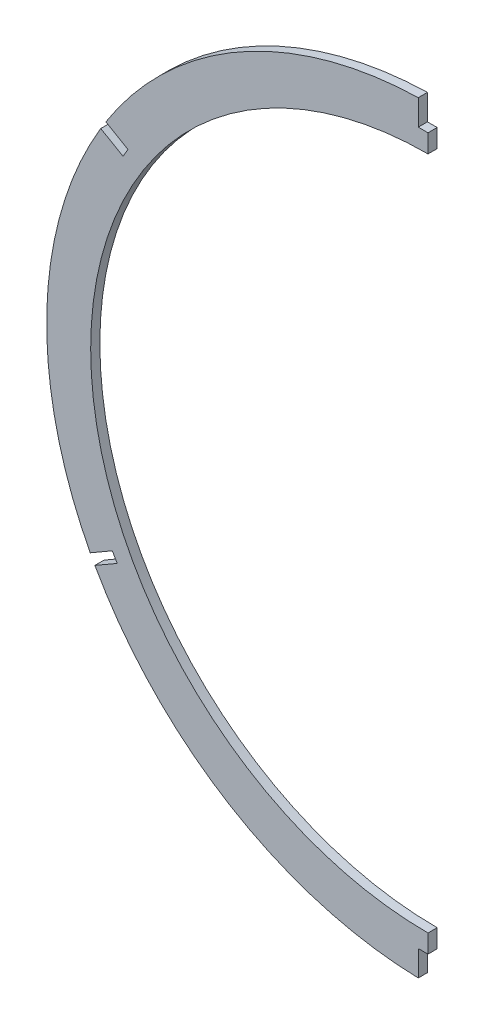
from build123d import *

# Parameters (mm, degrees)
SKETCH2_R           = 116.84
BOSS_EXTRUDE1_DEPTH = 1.5875
SKETCH3_W           = 232.210592103
SKETCH3_H           = 398.954583541
CUT_EXTRUDE1_DEPTH  = 133.08
SKETCH4_W           = 3.3782
SKETCH4_H           = 10.16
CUT_EXTRUDE2_DEPTH  = 4.175


with BuildPart() as part:
    # Sketch2 → Boss-Extrude1 (new body, symmetric)
    with BuildSketch(Plane.XY):
        with BuildLine():
            ThreePointArc((-1.651, 128.513680847), (-113.443755652, 64.087482344), (-116.974071472, -64.89271823))
            ThreePointArc((-116.974071472, -64.89271823), (-116.588202689, -65.623039511), (-116.197774242, -66.350933404))
            ThreePointArc((-116.197774242, -66.350933404), (-115.802941233, -67.076116512), (-115.403582459, -67.798817153))
            ThreePointArc((-115.403582459, -67.798817153), (0, -135.636), (115.403582459, -67.798817153))
            ThreePointArc((115.403582459, -67.798817153), (115.802941375, -67.076116254), (116.197774523, -66.350932884))
            ThreePointArc((116.197774523, -66.350932884), (116.588202828, -65.62303925), (116.974071472, -64.89271823))
            ThreePointArc((116.974071472, -64.89271823), (113.443755652, 64.087482344), (1.651, 128.513680847))
            ThreePointArc((1.651, 128.513680847), (0.825516124, 128.521420187), (0, 128.524))
            ThreePointArc((0, 128.524), (-0.825516124, 128.521420187), (-1.651, 128.513680847))
        make_face()
        with Locations((0, -3.556)):
            Circle(SKETCH2_R, mode=Mode.SUBTRACT)
    extrude(amount=BOSS_EXTRUDE1_DEPTH, both=True)

    # Sketch3 → Cut-Extrude1 (cut, through all)
    with BuildSketch(Plane(origin=(0, 0, 0), x_dir=(0, 0, -1), z_dir=(1, 0, 0))):
        with Locations((6.714523145, -6.913261573)):
            Rectangle(SKETCH3_W, SKETCH3_H)
    extrude(amount=CUT_EXTRUDE1_DEPTH, mode=Mode.SUBTRACT)

    # Sketch4 → Cut-Extrude2 (cut, through all)
    with BuildSketch(Plane.XY.offset(1.5875)):
        with Locations((-1.6891, 124.714)):
            Rectangle(SKETCH4_W, SKETCH4_H)
        Polygon((-105.620566898, 59.765541567), (-103.931466898, 62.691148586), (-112.730285, 67.771148586), (-114.419385, 64.845541567), align=None)
        with Locations((-1.6891, -131.826)):
            Rectangle(SKETCH4_W, SKETCH4_H)
        Polygon((-107.648347053, -63.365323312), (-109.337447053, -60.439716293), (-118.136265155, -65.519716293), (-116.447165155, -68.445323312), align=None)
    extrude(amount=-CUT_EXTRUDE2_DEPTH, mode=Mode.SUBTRACT)


solid = part.part
